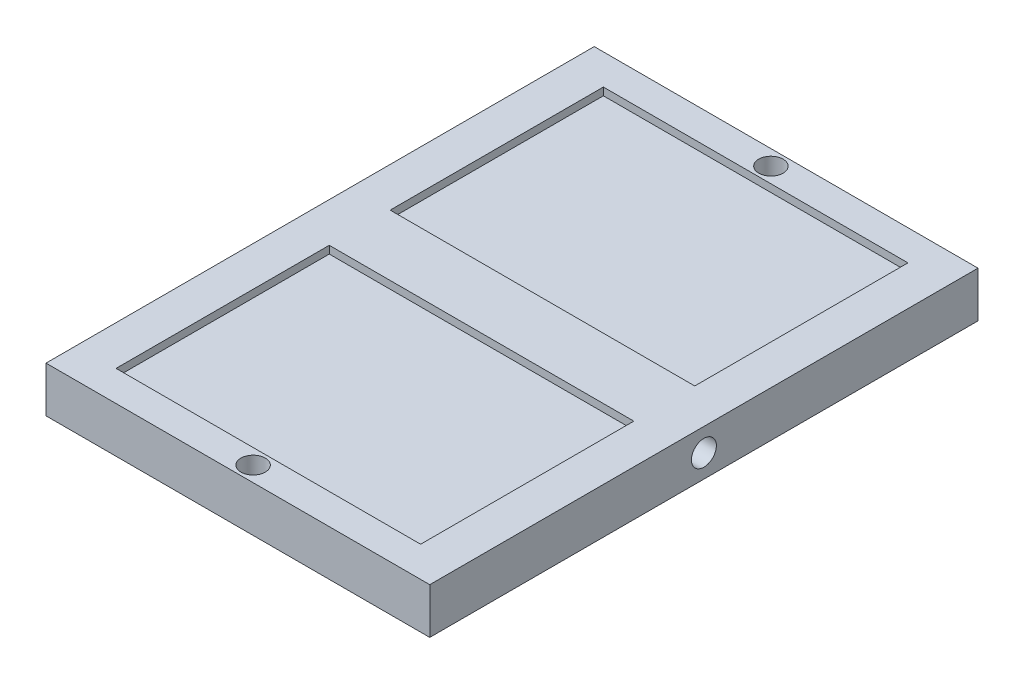
from build123d import *

# Parameters (mm, degrees)
SKETCH1_W               = 126
SKETCH1_H               = 180
BOSS_EXTRUDE1_DEPTH     = 15
SKETCH2_W               = 100
SKETCH2_H               = 70
CUT_EXTRUDE1_DEPTH      = 2.5
SKETCH4_R               = 4
CUT_EXTRUDE3_DEPTH      = 32.5
SKETCH5_R               = 4.1
CUT_EXTRUDE4_DEPTH      = 64
CUT_EXTRUDE4_DEPTH_BACK = 64


with BuildPart() as part:
    # Sketch1 → Boss-Extrude1 (new body)
    with BuildSketch(Plane(origin=(0, 0, 0), x_dir=(1, 0, 0), z_dir=(0, 1, 0))):
        Rectangle(SKETCH1_W, SKETCH1_H)
    extrude(amount=BOSS_EXTRUDE1_DEPTH)

    # Sketch2 → Cut-Extrude1 (cut)
    with BuildSketch(Plane(origin=(0, 15, 0), x_dir=(1, 0, 0), z_dir=(0, 1, 0))):
        with Locations((0, -45)):
            Rectangle(SKETCH2_W, SKETCH2_H)
        with Locations((0, 45)):
            Rectangle(SKETCH2_W, SKETCH2_H)
    extrude(amount=-CUT_EXTRUDE1_DEPTH, mode=Mode.SUBTRACT)

    # Sketch4 → Cut-Extrude3 (cut)
    with BuildSketch(Plane(origin=(0, 0, 0), x_dir=(1, 0, 0), z_dir=(0, 1, 0))):
        with Locations((0, -85)):
            Circle(SKETCH4_R)
        with Locations((0, 85)):
            Circle(SKETCH4_R)
    extrude(amount=CUT_EXTRUDE3_DEPTH, mode=Mode.SUBTRACT)

    # Sketch5 → Cut-Extrude4 (cut, two sides)
    with BuildSketch(Plane(origin=(0, 0, 0), x_dir=(0, 0, -1), z_dir=(1, 0, 0))) as cut_extrude4_sk:
        with Locations((0, 7.5)):
            Circle(SKETCH5_R)
    extrude(amount=CUT_EXTRUDE4_DEPTH, mode=Mode.SUBTRACT)
    extrude(cut_extrude4_sk.sketch, amount=-CUT_EXTRUDE4_DEPTH_BACK, mode=Mode.SUBTRACT)


solid = part.part
